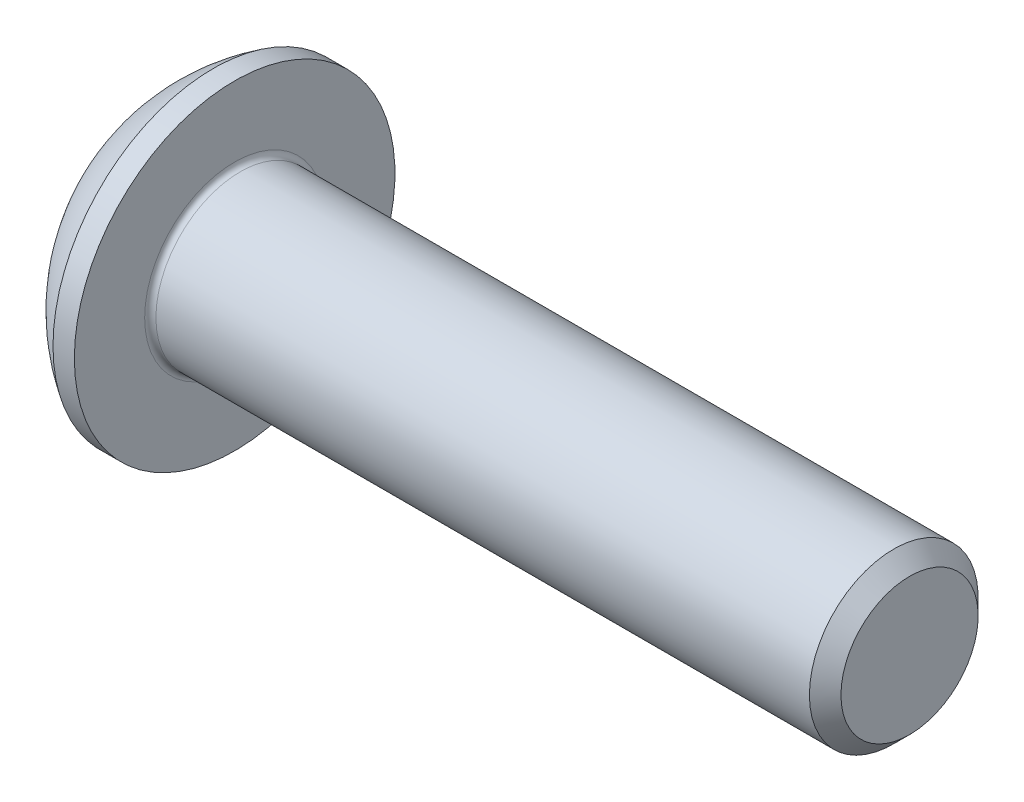
from build123d import *

# Parameters (mm, degrees)
FILLET1_R   = 0.1
HEX_2_DEPTH = 1.04


with BuildPart() as part:
    # BodySke → BaseBody (revolve)
    with BuildSketch(Plane.XY):
        with BuildLine():
            Line((13.65, 0), (13.65, 1.2195))
            Line((13.65, 1.2195), (13.3695, 1.5))
            Line((13.3695, 1.5), (1.65, 1.5))
            Line((1.65, 1.5), (1.65, 2.85))
            Line((1.65, 2.85), (1.27, 2.85))
            ThreePointArc((1.27, 2.85), (0.53140404, 2.229827628), (0, 1.425))
            Line((0, 1.425), (0, 0))
            Line((0, 0), (13.65, 0))
        make_face()
    revolve(axis=Axis((0, 0, 0), (1, 0, 0)))

    # Fillet1
    fillet1_edges = [part.edges().sort_by_distance(p)[0] for p in [
        (1.65, -1.5, 0),
    ]]
    fillet(fillet1_edges, radius=FILLET1_R)

    # Sketch2 → PreBroach (revolve, cut)
    with BuildSketch(Plane.XY):
        Polygon((0, 1), (1.04, 1), (1.617350269, 0), (0, 0), align=None)
    revolve(axis=Axis((0, 0, 0), (1, 0, 0)), mode=Mode.SUBTRACT)

    # Sketch3 → Hex 2 (cut)
    with BuildSketch(Plane(origin=(0, 0, 0), x_dir=(0, 0, -1), z_dir=(1, 0, 0))):
        Polygon((-1, -0.577350269), (-1, 0.577350269), (0, 1.154700538), (1, 0.577350269), (1, -0.577350269), (0, -1.154700538), align=None)
    extrude(amount=HEX_2_DEPTH, mode=Mode.SUBTRACT)


solid = part.part
